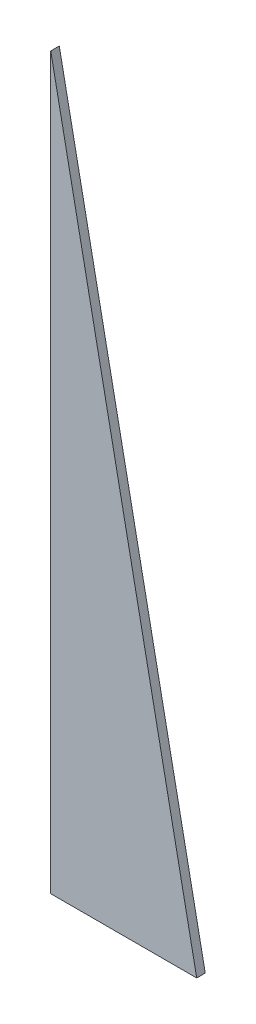
from build123d import *

# Parameters (mm, degrees)
BOSS_EXTRUDE1_DEPTH = 2


with BuildPart() as part:
    # Sketch1 → Boss-Extrude1 (new body)
    with BuildSketch(Plane.XY):
        Polygon((-531.680672269, -144.415966387), (-531.680672269, -315.415966387), (-497.480672269, -315.415966387), align=None)
    extrude(amount=BOSS_EXTRUDE1_DEPTH)


solid = part.part
